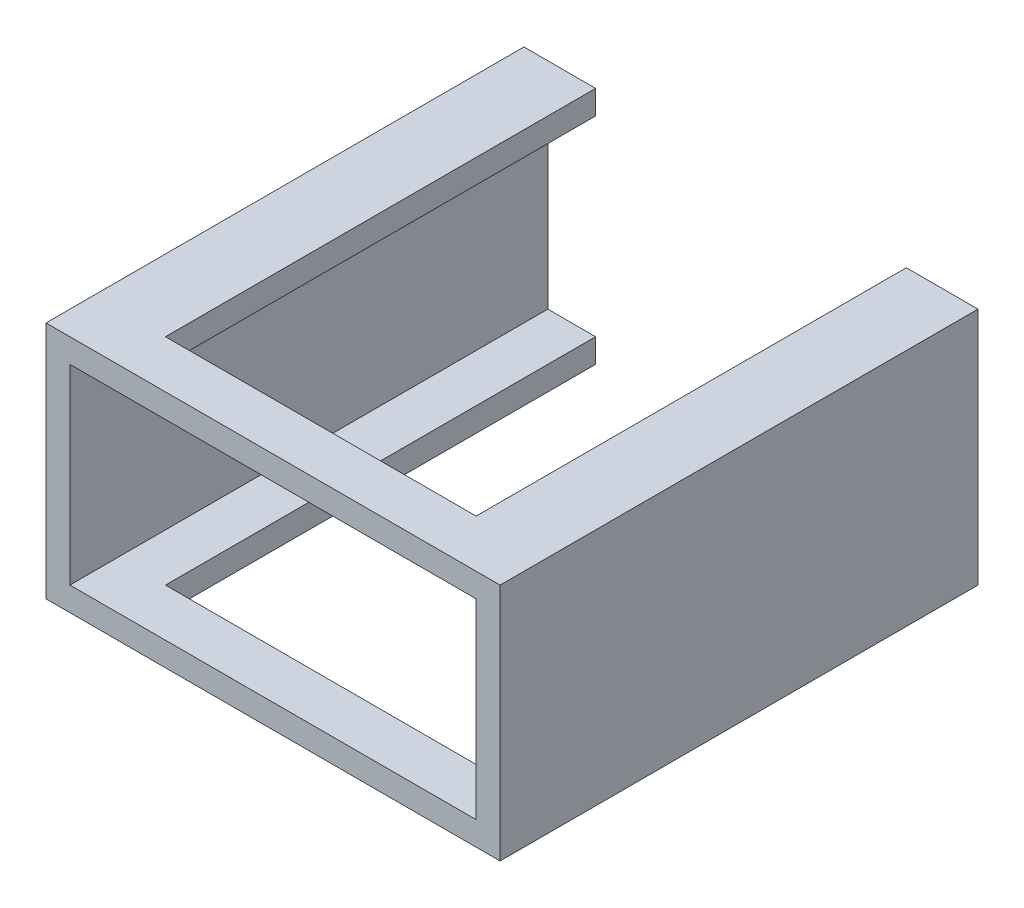
from build123d import *

# Parameters (mm, degrees)
BOSS_EXTRUDE1_DEPTH      = 10
BOSS_EXTRUDE1_DEPTH_BACK = 10
SKETCH1_W                = 19
SKETCH1_H                = 10
SKETCH2_W                = 17
SKETCH2_H                = 8
CUT_EXTRUDE1_DEPTH       = 20
CUT_EXTRUDE3_DEPTH       = 8
CUT_EXTRUDE3_DEPTH_BACK  = 10
SKETCH3_W                = 13
SKETCH3_H                = 10.51996768


with BuildPart() as part:
    # Sketch1 → Boss-Extrude1 (new, two sides: drawn at the far end of the back side and taken through both)
    with BuildSketch(Plane.XY.offset(-BOSS_EXTRUDE1_DEPTH_BACK)):
        with Locations((-0.130136986, 2.22260274)):
            Rectangle(SKETCH1_W, SKETCH1_H)
    extrude(amount=BOSS_EXTRUDE1_DEPTH + BOSS_EXTRUDE1_DEPTH_BACK)

    # Sketch2 → Cut-Extrude1 (cut)
    with BuildSketch(Plane.XY.offset(10)):
        with Locations((-0.130136986, 2.22260274)):
            Rectangle(SKETCH2_W, SKETCH2_H)
    extrude(amount=-CUT_EXTRUDE1_DEPTH, mode=Mode.SUBTRACT)

    # Sketch3 → Cut-Extrude3 (cut, two sides: drawn at the far end of the back side and taken through both)
    with BuildSketch(Plane.XY.offset(-CUT_EXTRUDE3_DEPTH_BACK)):
        with Locations((-0.130136986, 2.34516547)):
            Rectangle(SKETCH3_W, SKETCH3_H)
    extrude(amount=CUT_EXTRUDE3_DEPTH + CUT_EXTRUDE3_DEPTH_BACK, mode=Mode.SUBTRACT)


solid = part.part
